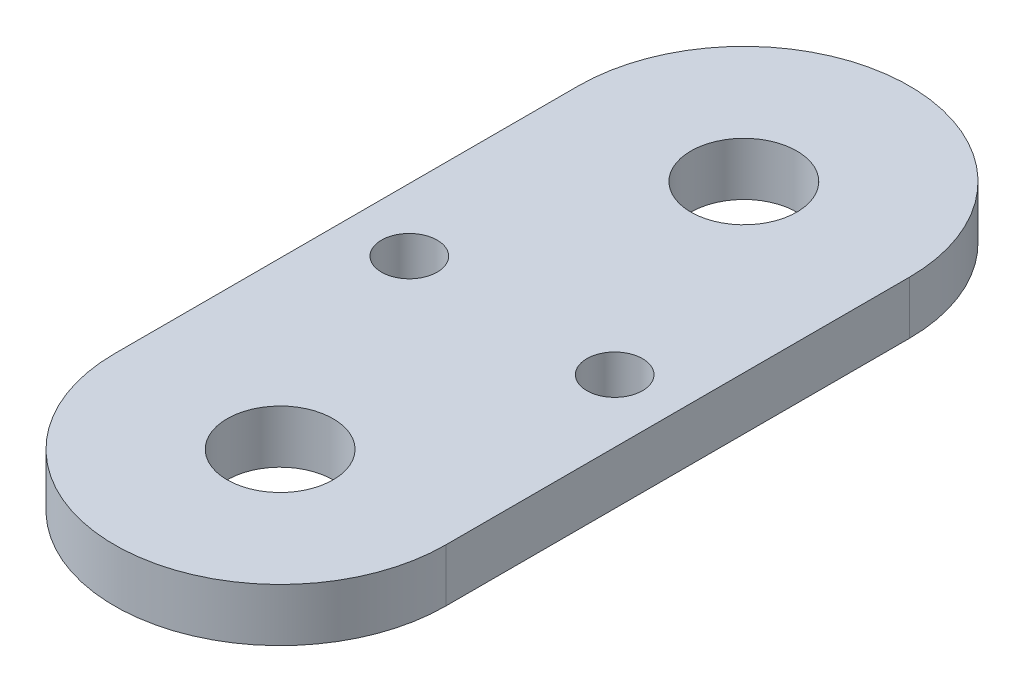
from build123d import *

# Parameters (mm, degrees)
SKETCH1_R           = 12.5
SKETCH1_R_2         = 4
SKETCH1_R_3         = 2.1
BOSS_EXTRUDE1_DEPTH = 4


with BuildPart() as part:
    # Sketch1 → Boss-Extrude1 (new body)
    with BuildSketch(Plane(origin=(0, 0, 0), x_dir=(1, 0, 0), z_dir=(0, 1, 0))):
        with Locations((0, 17.5)):
            Circle(SKETCH1_R)
        with Locations((0, 17.5)):
            Circle(SKETCH1_R_2, mode=Mode.SUBTRACT)
        with BuildLine():
            ThreePointArc((-12.5, -17.5), (0, -5), (12.5, -17.5))
            Line((12.5, -17.5), (12.5, 17.5))
            ThreePointArc((12.5, 17.5), (-1.8e-08, 5), (-12.5, 17.500000037))
            Line((-12.5, 17.500000037), (-12.5, -17.5))
        make_face()
        with Locations((-7.75, 0)):
            Circle(SKETCH1_R_3, mode=Mode.SUBTRACT)
        with Locations((7.75, 0)):
            Circle(SKETCH1_R_3, mode=Mode.SUBTRACT)
        with Locations((0, -17.5)):
            Circle(SKETCH1_R)
        with Locations((0, -17.5)):
            Circle(SKETCH1_R_2, mode=Mode.SUBTRACT)
    extrude(amount=BOSS_EXTRUDE1_DEPTH)


solid = part.part
